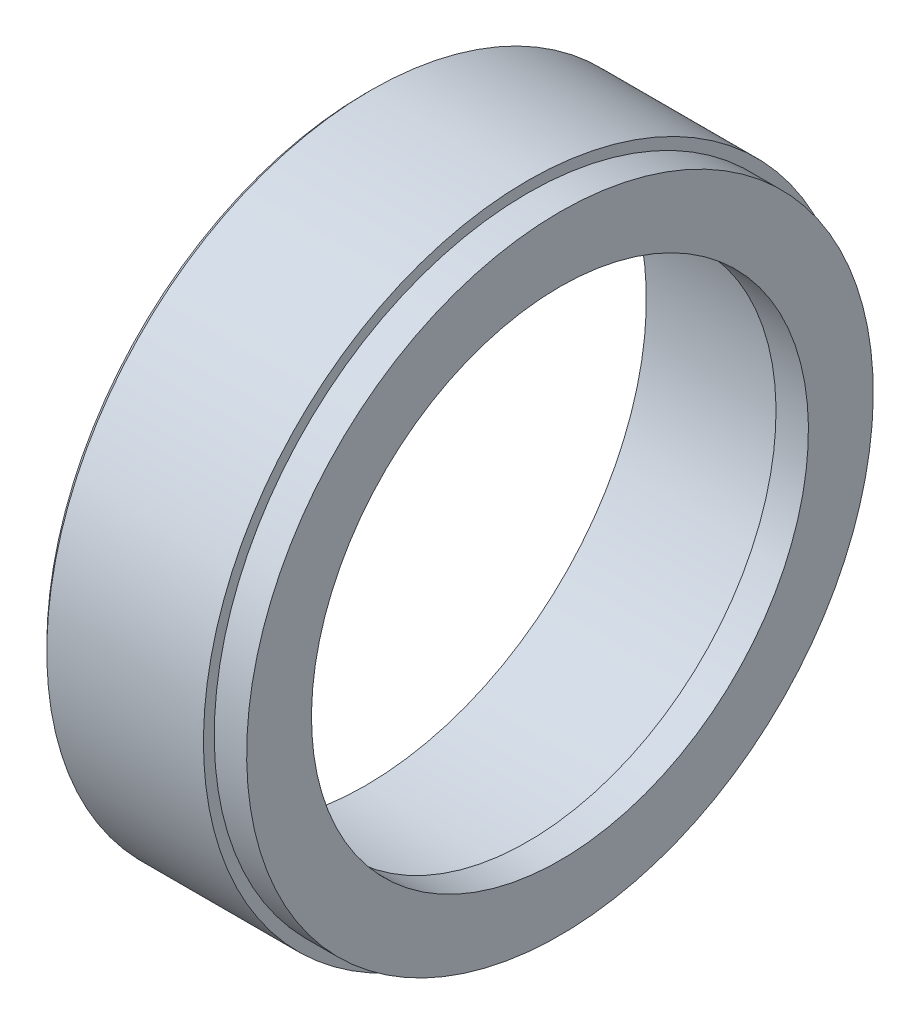
from build123d import *

# Parameters (mm, degrees)
CHAMFER_1_SIZE = 0.5


with BuildPart() as part:
    # Эскиз1 → Повернуть1 (revolve)
    with BuildSketch(Plane.XY):
        Polygon((-98.05, 23), (-101.05, 23), (-101.05, 26), (-116.05, 26), (-116.05, 30), (-101.05, 30), (-101.05, 29), (-98.05, 29), align=None)
    revolve(axis=Axis((-108.55, 0, 0), (-1, 0, 0)))

    # Фаска1
    chamfer_1_edges = [part.edges().sort_by_distance(p)[0] for p in [
        (-116.05, -30, 0),
    ]]
    chamfer(chamfer_1_edges, length=CHAMFER_1_SIZE)


solid = part.part
